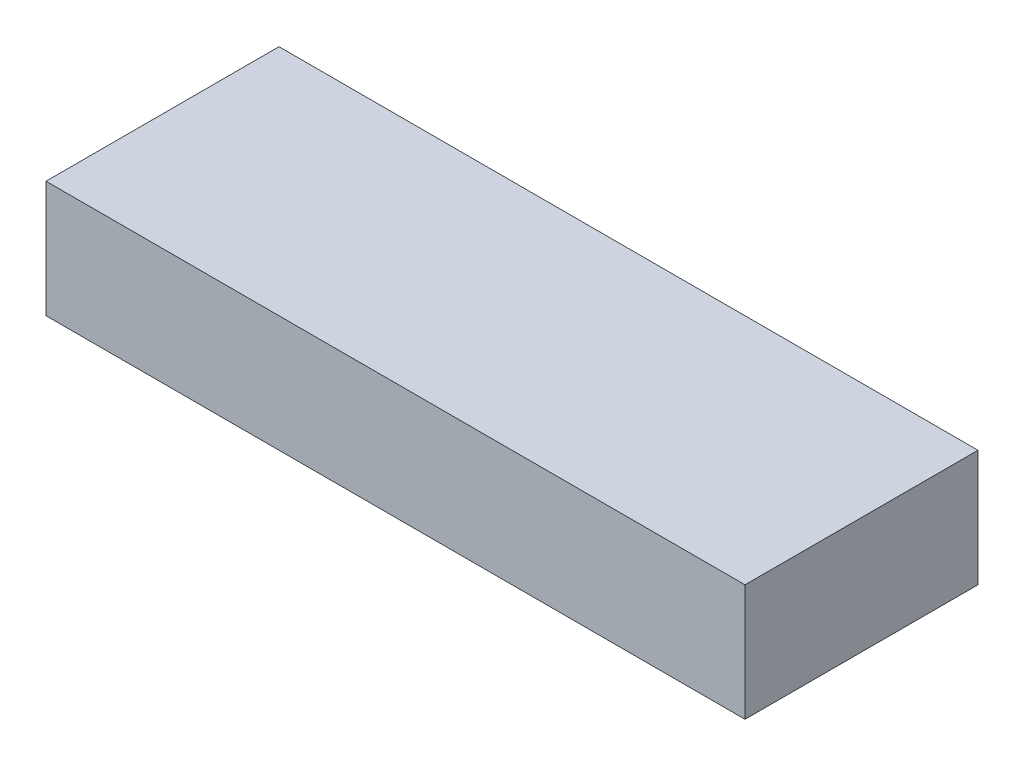
from build123d import *

# Parameters (mm, degrees)
SKETCH1_W             = 38.1
SKETCH1_H             = 12.7
BOSS_EXTRUDE1_DEPTH   = 6.35
BOSS_EXTRUDE2_DEPTH   = 0.508
BOSS_EXTRUDE2_2_DEPTH = 0.508
BOSS_EXTRUDE2_3_DEPTH = 0.508
BOSS_EXTRUDE2_4_DEPTH = 0.508
BOSS_EXTRUDE2_5_DEPTH = 0.508
BOSS_EXTRUDE2_6_DEPTH = 0.508
BOSS_EXTRUDE2_7_DEPTH = 0.508


with BuildPart() as part:
    # Sketch1 → Boss-Extrude1 (new body)
    with BuildSketch(Plane(origin=(0, 0, 0), x_dir=(1, 0, 0), z_dir=(0, 1, 0))):
        Rectangle(SKETCH1_W, SKETCH1_H)
    extrude(amount=BOSS_EXTRUDE1_DEPTH)


with BuildPart() as body_2:
    # Sketch2 → Boss-Extrude2 (new body)
    with BuildSketch(Plane(origin=(0, 6.35, 0), x_dir=(1, 0, 0), z_dir=(0, 1, 0))):
        with BuildLine():
            Line((-10.818339769, -1.769760205), (-10.818339769, 2.463573129))
            Line((-10.818339769, 2.463573129), (-10.139920966, 2.463573129))
            add(Edge.make_bspline(
                [(-10.139920966, 2.463573129), (-10.092427408, 2.463578549), (-10.000528273, 2.463589037), (-9.867941805, 2.458933035), (-9.744979053, 2.452909976), (-9.632031333, 2.446171573), (-9.528906399, 2.434559958), (-9.43576107, 2.422322585), (-9.352409241, 2.407565067), (-9.300877334, 2.394327116), (-9.276633039, 2.388099037)],
                knots=[0, 0, 0, 0, 0.00014247, 0.000275678, 0.000397937, 0.000511828, 0.00061503, 0.000709176, 0.000793672, 0.000868745, 0.000868745, 0.000868745, 0.000868745], degree=3))
            add(Edge.make_bspline(
                [(-9.276633039, 2.388099037), (-9.244797817, 2.37931422), (-9.182326894, 2.36207559), (-9.092848595, 2.327261432), (-9.007965947, 2.288563026), (-8.927782589, 2.244415383), (-8.852790879, 2.194285517), (-8.783275812, 2.137775582), (-8.717738118, 2.077153885), (-8.658504892, 2.010730915), (-8.604967816, 1.940542744), (-8.558453695, 1.866607761), (-8.518038886, 1.790056483), (-8.485696452, 1.70992556), (-8.461327036, 1.626584019), (-8.443503347, 1.54038774), (-8.431951183, 1.451063977), (-8.430859655, 1.390294102), (-8.430305581, 1.359446526)],
                knots=[0, 0, 0, 0, 9.9016e-05, 0.0001943, 0.000287645, 0.000378743, 0.00046859, 0.000557854, 0.000647251, 0.000736128, 0.000824493, 0.000911778, 0.00099788, 0.001083862, 0.00117053, 0.001258013, 0.001347735, 0.001440232, 0.001440232, 0.001440232, 0.001440232], degree=3))
            add(Edge.make_bspline(
                [(-8.430305581, 1.359446526), (-8.43175432, 1.319815488), (-8.434605983, 1.241806659), (-8.452822602, 1.127225802), (-8.486981601, 1.018930423), (-8.53167782, 0.914924679), (-8.592450704, 0.815596513), (-8.669620513, 0.720993151), (-8.761937349, 0.628201616), (-8.832749459, 0.572579349), (-8.869581756, 0.543647915)],
                knots=[0, 0, 0, 0, 0.000118917, 0.000234073, 0.000346736, 0.000458759, 0.000572927, 0.000694772, 0.000824295, 0.00096469, 0.00096469, 0.00096469, 0.00096469], degree=3))
            add(Edge.make_bspline(
                [(-8.869581756, 0.543647915), (-8.839734629, 0.528411215), (-8.781212671, 0.498536263), (-8.698128683, 0.44943076), (-8.621201979, 0.397200829), (-8.550087643, 0.342897358), (-8.486277381, 0.284218344), (-8.427136359, 0.224544953), (-8.375582288, 0.160458147), (-8.329481084, 0.094242102), (-8.289410667, 0.024938002), (-8.254513752, -0.047337114), (-8.225037579, -0.122830154), (-8.200076394, -0.201156918), (-8.181460336, -0.282586815), (-8.16932227, -0.367148967), (-8.160028608, -0.454554975), (-8.159305648, -0.514093764), (-8.15893806, -0.544366241)],
                knots=[0, 0, 0, 0, 0.000100519, 0.000197089, 0.00028929, 0.00037936, 0.000465212, 0.00054917, 0.000631153, 0.000711603, 0.000791019, 0.000871049, 0.000952149, 0.001033952, 0.001117472, 0.001202385, 0.001290142, 0.001380916, 0.001380916, 0.001380916, 0.001380916], degree=3))
            add(Edge.make_bspline(
                [(-8.15893806, -0.544366241), (-8.161323464, -0.602184941), (-8.166031049, -0.716289914), (-8.200450614, -0.883822219), (-8.260123203, -1.04265804), (-8.340251186, -1.192166095), (-8.438984277, -1.328018371), (-8.552499018, -1.447023785), (-8.679652577, -1.547759226), (-8.796967103, -1.615747834), (-8.89843493, -1.661374548), (-8.982478834, -1.689583859), (-9.072740207, -1.715716923), (-9.170872419, -1.7340681), (-9.275096466, -1.750865115), (-9.386428541, -1.76123594), (-9.504660564, -1.768263993), (-9.585867429, -1.769251384), (-9.627714769, -1.769760205)],
                knots=[0, 0, 0, 0, 0.000173404, 0.000342212, 0.000510447, 0.000680801, 0.000849577, 0.00101272, 0.001172709, 0.001334592, 0.001418113, 0.001506079, 0.001600316, 0.00169977, 0.001805314, 0.001916951, 0.002035021, 0.002160555, 0.002160555, 0.002160555, 0.002160555], degree=3))
            Line((-9.627714769, -1.769760205), (-10.818339769, -1.769760205))
        make_face()
        with BuildLine():
            Line((-10.058510709, 1.703744069), (-10.058510709, 0.781094496))
            Line((-10.058510709, 0.781094496), (-9.856681115, 0.781094496))
            add(Edge.make_bspline(
                [(-9.856681115, 0.781094496), (-9.82925066, 0.7813337), (-9.776297827, 0.781795469), (-9.699813075, 0.78774289), (-9.628694608, 0.79788956), (-9.563212163, 0.812046717), (-9.502755746, 0.830024242), (-9.447711571, 0.851655076), (-9.398321657, 0.878047045), (-9.340942, 0.917359048), (-9.280287564, 0.975208419), (-9.226894147, 1.058783823), (-9.195445781, 1.154895218), (-9.191943281, 1.222680417), (-9.190134641, 1.257683706)],
                knots=[0, 0, 0, 0, 8.2276e-05, 0.000158828, 0.000229946, 0.000297645, 0.00035962, 0.000418988, 0.000474758, 0.000527212, 0.000627369, 0.000723824, 0.000821975, 0.000926777, 0.000926777, 0.000926777, 0.000926777], degree=3))
            add(Edge.make_bspline(
                [(-9.190134641, 1.257683706), (-9.191581884, 1.290470101), (-9.19438007, 1.35386128), (-9.226044532, 1.44286814), (-9.2752257, 1.521746435), (-9.333290982, 1.575732177), (-9.387970728, 1.612602847), (-9.434790882, 1.636880614), (-9.486179517, 1.658613822), (-9.543131462, 1.675231563), (-9.605321489, 1.68770093), (-9.672447508, 1.696858187), (-9.744625333, 1.703091006), (-9.79447871, 1.703521712), (-9.820216105, 1.703744069)],
                knots=[0, 0, 0, 0, 9.7968e-05, 0.000189417, 0.000279758, 0.000374532, 0.00042463, 0.000477358, 0.000532479, 0.000591774, 0.000654974, 0.000722614, 0.00079494, 0.000872128, 0.000872128, 0.000872128, 0.000872128], degree=3))
            Line((-9.820216105, 1.703744069), (-10.058510709, 1.703744069))
        make_face(mode=Mode.SUBTRACT)
        with BuildLine():
            Line((-10.058510709, 0.075538941), (-10.058510709, -1.009931145))
            Line((-10.058510709, -1.009931145), (-9.839720645, -1.009931145))
            add(Edge.make_bspline(
                [(-9.839720645, -1.009931145), (-9.796465571, -1.00968403), (-9.713302293, -1.009208922), (-9.594171045, -1.003468478), (-9.485850958, -0.993122341), (-9.388629039, -0.980206022), (-9.302356374, -0.96270643), (-9.227324586, -0.940457942), (-9.16250471, -0.915980729), (-9.108285411, -0.885748466), (-9.063991349, -0.850565608), (-9.024020603, -0.814607882), (-8.991430947, -0.773127248), (-8.965645403, -0.727904355), (-8.94332806, -0.680062572), (-8.929867815, -0.627733694), (-8.919619657, -0.572468624), (-8.919055673, -0.53424297), (-8.91876712, -0.514685418)],
                knots=[0, 0, 0, 0, 0.000129759, 0.000249477, 0.000357656, 0.000456118, 0.0005436, 0.000621415, 0.000690705, 0.000751081, 0.000806716, 0.000860114, 0.000912031, 0.0009641, 0.001016107, 0.001069807, 0.001125713, 0.001184282, 0.001184282, 0.001184282, 0.001184282], degree=3))
            add(Edge.make_bspline(
                [(-8.91876712, -0.514685418), (-8.919403463, -0.49232105), (-8.920642887, -0.448761277), (-8.930765283, -0.38509402), (-8.949160983, -0.325656412), (-8.972331265, -0.268928552), (-9.004573943, -0.216941495), (-9.042893264, -0.167896166), (-9.089192786, -0.123453393), (-9.1412593, -0.080925109), (-9.201989733, -0.043689292), (-9.271412579, -0.011380626), (-9.34990498, 0.015602383), (-9.437710075, 0.037086272), (-9.534442933, 0.055319351), (-9.640809598, 0.066206513), (-9.755924211, 0.074303773), (-9.835746557, 0.075117863), (-9.87703368, 0.075538941)],
                knots=[0, 0, 0, 0, 6.708e-05, 0.000130653, 0.000192629, 0.000253427, 0.000313928, 0.000375514, 0.000439678, 0.00050603, 0.000576864, 0.000652738, 0.00073534, 0.000825427, 0.000923728, 0.001030394, 0.001145977, 0.001269815, 0.001269815, 0.001269815, 0.001269815], degree=3))
            Line((-9.87703368, 0.075538941), (-10.058510709, 0.075538941))
        make_face(mode=Mode.SUBTRACT)
    extrude(amount=-BOSS_EXTRUDE2_DEPTH)


with BuildPart() as body_3:
    # Sketch2 → Boss-Extrude2 2 (new body)
    with BuildSketch(Plane(origin=(0, 6.35, 0), x_dir=(1, 0, 0), z_dir=(0, 1, 0))):
        Polygon((-6.095696874, 2.463573129), (-5.390989342, 2.463573129), (-3.681373957, -1.769760205), (-4.492932451, -1.769760205), (-4.821965571, -0.901384136), (-6.666416692, -0.901384136), (-6.995449812, -1.769760205), (-7.806160282, -1.769760205), align=None)
        Polygon((-5.74376712, 1.328069656), (-6.378088701, -0.141555076), (-5.109445539, -0.141555076), align=None, mode=Mode.SUBTRACT)
    extrude(amount=-BOSS_EXTRUDE2_2_DEPTH)


with BuildPart() as body_4:
    # Sketch2 → Boss-Extrude2 3 (new body)
    with BuildSketch(Plane(origin=(0, 6.35, 0), x_dir=(1, 0, 0), z_dir=(0, 1, 0))):
        Polygon((-3.491416692, 2.463573129), (-1.211929513, 2.463573129), (-1.211929513, 1.703744069), (-1.971758573, 1.703744069), (-1.971758573, -1.769760205), (-2.731587633, -1.769760205), (-2.731587633, 1.703744069), (-3.491416692, 1.703744069), align=None)
    extrude(amount=-BOSS_EXTRUDE2_3_DEPTH)


with BuildPart() as body_5:
    # Sketch2 → Boss-Extrude2 4 (new body)
    with BuildSketch(Plane(origin=(0, 6.35, 0), x_dir=(1, 0, 0), z_dir=(0, 1, 0))):
        Polygon((-1.049109, 2.463573129), (1.230378179, 2.463573129), (1.230378179, 1.703744069), (0.47054912, 1.703744069), (0.47054912, -1.769760205), (-0.28927994, -1.769760205), (-0.28927994, 1.703744069), (-1.049109, 1.703744069), align=None)
    extrude(amount=-BOSS_EXTRUDE2_4_DEPTH)


with BuildPart() as body_6:
    # Sketch2 → Boss-Extrude2 5 (new body)
    with BuildSketch(Plane(origin=(0, 6.35, 0), x_dir=(1, 0, 0), z_dir=(0, 1, 0))):
        Polygon((1.827386726, 2.463573129), (4.106873906, 2.463573129), (4.106873906, 1.703744069), (2.587215786, 1.703744069), (2.587215786, 0.889641505), (4.106873906, 0.889641505), (4.106873906, 0.129812445), (2.587215786, 0.129812445), (2.587215786, -1.009931145), (4.106873906, -1.009931145), (4.106873906, -1.769760205), (1.827386726, -1.769760205), align=None)
    extrude(amount=-BOSS_EXTRUDE2_5_DEPTH)


with BuildPart() as body_7:
    # Sketch2 → Boss-Extrude2 6 (new body)
    with BuildSketch(Plane(origin=(0, 6.35, 0), x_dir=(1, 0, 0), z_dir=(0, 1, 0))):
        with BuildLine():
            Line((4.866702966, 2.463573129), (5.752039504, 2.463573129))
            add(Edge.make_bspline(
                [(5.752039504, 2.463573129), (5.81055998, 2.463365415), (5.923111339, 2.462965922), (6.085404251, 2.456662985), (6.23449261, 2.44789193), (6.370597155, 2.434507069), (6.493659657, 2.41676036), (6.603803453, 2.395839928), (6.701025326, 2.371996609), (6.786145206, 2.342285953), (6.862961689, 2.308772784), (6.934565331, 2.270265538), (7.002535814, 2.227193006), (7.066418829, 2.178421832), (7.126769535, 2.124829398), (7.183701787, 2.066361759), (7.236411079, 2.002523132), (7.284571034, 1.933716897), (7.328464956, 1.861334315), (7.367257977, 1.785276005), (7.398804526, 1.705489073), (7.426679284, 1.623126614), (7.446756569, 1.537011239), (7.460720027, 1.447981296), (7.470943524, 1.35572339), (7.471531327, 1.293047466), (7.471831171, 1.2610758)],
                knots=[0, 0, 0, 0, 0.000175549, 0.00033763, 0.000487174, 0.000623534, 0.00074778, 0.000860044, 0.000959797, 0.001047763, 0.001130165, 0.001210977, 0.001291432, 0.001371318, 0.001451813, 0.001533373, 0.001615893, 0.001699886, 0.001785112, 0.001869685, 0.001955666, 0.002042285, 0.00213032, 0.002220522, 0.002312582, 0.002408443, 0.002408443, 0.002408443, 0.002408443], degree=3))
            add(Edge.make_bspline(
                [(7.471831171, 1.2610758), (7.471052283, 1.227704725), (7.469525027, 1.16227013), (7.461298392, 1.066152046), (7.446262687, 0.974192987), (7.423488926, 0.886662197), (7.397313445, 0.802470253), (7.36250677, 0.72317055), (7.323223996, 0.647609788), (7.276568994, 0.576856803), (7.225367409, 0.509340029), (7.165821042, 0.447646286), (7.101787584, 0.388459766), (7.02966748, 0.335487715), (6.952639852, 0.285148351), (6.869174242, 0.239527482), (6.779815375, 0.197478304), (6.716991666, 0.174028777), (6.684865359, 0.162037338)],
                knots=[0, 0, 0, 0, 0.000100124, 0.000196325, 0.000289175, 0.000379262, 0.000467493, 0.000553344, 0.000638696, 0.000722668, 0.000807309, 0.000892492, 0.000979541, 0.001068584, 0.001160554, 0.001255442, 0.001353703, 0.001456538, 0.001456538, 0.001456538, 0.001456538], degree=3))
            Line((6.684865359, 0.162037338), (7.661788436, -1.769760205))
            Line((7.661788436, -1.769760205), (6.817157026, -1.769760205))
            Line((6.817157026, -1.769760205), (5.884331171, 0.075538941))
            Line((5.884331171, 0.075538941), (5.626532026, 0.075538941))
            Line((5.626532026, 0.075538941), (5.626532026, -1.769760205))
            Line((5.626532026, -1.769760205), (4.866702966, -1.769760205))
            Line((4.866702966, -1.769760205), (4.866702966, 2.463573129))
        make_face()
        with BuildLine():
            Line((5.626532026, 0.835368), (5.922492229, 0.835368))
            add(Edge.make_bspline(
                [(5.922492229, 0.835368), (5.958675824, 0.835775524), (6.027959633, 0.836555845), (6.127598851, 0.840175297), (6.218095024, 0.848896386), (6.299836772, 0.859915157), (6.373235413, 0.872637919), (6.437636257, 0.890870409), (6.494031622, 0.910406984), (6.541753222, 0.934685879), (6.58252546, 0.962296248), (6.617729678, 0.993662314), (6.646848615, 1.029964542), (6.670814984, 1.070216392), (6.689458214, 1.114773885), (6.703066344, 1.163147878), (6.710671276, 1.215889414), (6.711546249, 1.252288255), (6.712002111, 1.271252082)],
                knots=[0, 0, 0, 0, 0.00010856, 0.00020787, 0.000299003, 0.000381157, 0.000455338, 0.000522203, 0.000581758, 0.000634096, 0.000682314, 0.000729148, 0.000774972, 0.000821366, 0.000869248, 0.000919453, 0.000971743, 0.001028617, 0.001028617, 0.001028617, 0.001028617], degree=3))
            add(Edge.make_bspline(
                [(6.712002111, 1.271252082), (6.711140262, 1.293687673), (6.709447321, 1.337758235), (6.692648078, 1.401204392), (6.665907313, 1.45992815), (6.629253048, 1.513664183), (6.583091767, 1.560772898), (6.530118054, 1.602299606), (6.46918861, 1.635135819), (6.41277253, 1.656794236), (6.361447084, 1.66975269), (6.315127488, 1.679409215), (6.261489117, 1.686253072), (6.200491477, 1.6935122), (6.132290053, 1.698219378), (6.056513107, 1.701654679), (5.973378269, 1.703060229), (5.915425391, 1.703509559), (5.885179194, 1.703744069)],
                knots=[0, 0, 0, 0, 6.7187e-05, 0.000131976, 0.000195351, 0.000260035, 0.000326007, 0.000392499, 0.000461195, 0.000532856, 0.000573171, 0.000619905, 0.000674712, 0.000735303, 0.000804181, 0.000879731, 0.000962855, 0.001053597, 0.001053597, 0.001053597, 0.001053597], degree=3))
            Line((5.885179194, 1.703744069), (5.626532026, 1.703744069))
            Line((5.626532026, 1.703744069), (5.626532026, 0.835368))
        make_face(mode=Mode.SUBTRACT)
    extrude(amount=-BOSS_EXTRUDE2_6_DEPTH)


with BuildPart() as body_8:
    # Sketch2 → Boss-Extrude2 7 (new body)
    with BuildSketch(Plane(origin=(0, 6.35, 0), x_dir=(1, 0, 0), z_dir=(0, 1, 0))):
        Polygon((7.933155957, 2.463573129), (8.778635391, 2.463573129), (9.534224333, 0.978683973), (10.289813276, 2.463573129), (11.135292709, 2.463573129), (9.914138863, 0.063666612), (9.914138863, -1.769760205), (9.154309803, -1.769760205), (9.154309803, 0.063666612), align=None)
    extrude(amount=-BOSS_EXTRUDE2_7_DEPTH)


solid = Compound([part.part, body_2.part, body_3.part, body_4.part, body_5.part, body_6.part, body_7.part, body_8.part])
